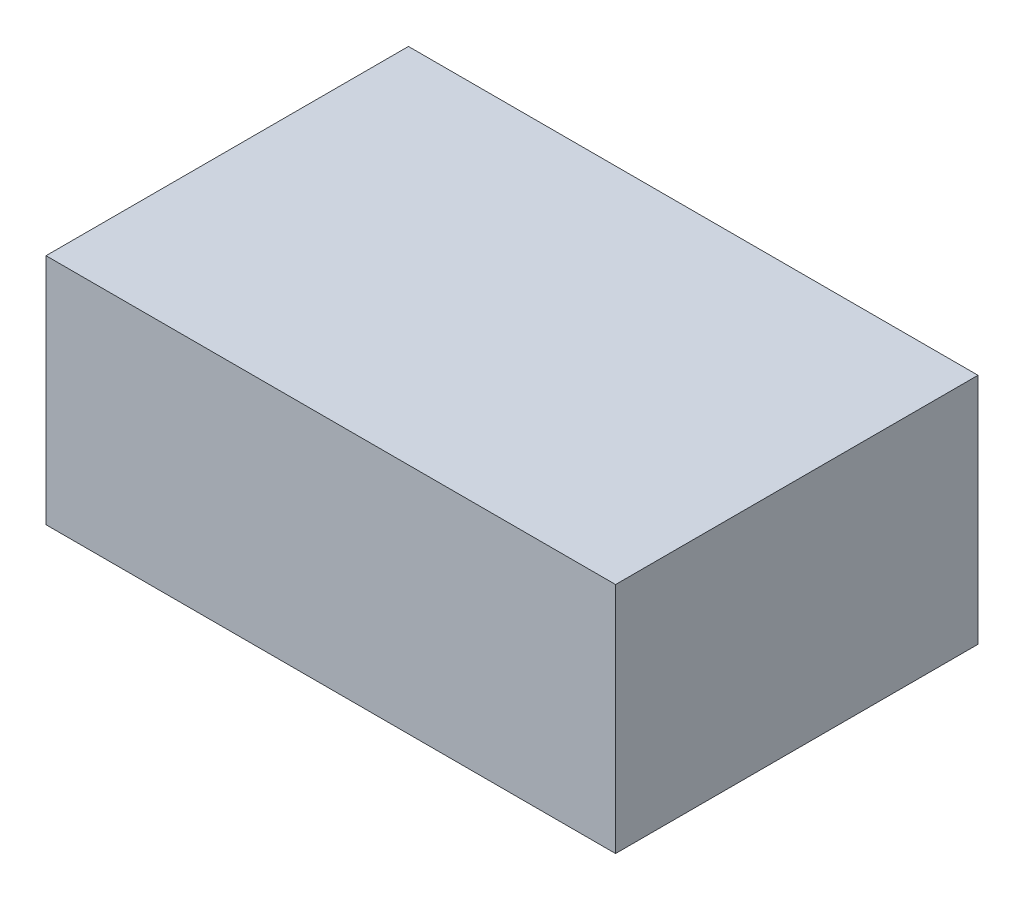
from build123d import *

# Parameters (mm, degrees)
SKETCH1_W           = 69.85
SKETCH1_H           = 44.45
BOSS_EXTRUDE1_DEPTH = 28.575


with BuildPart() as part:
    # Sketch1 → Boss-Extrude1 (new body)
    with BuildSketch(Plane(origin=(0, 0, 0), x_dir=(1, 0, 0), z_dir=(0, 1, 0))):
        Rectangle(SKETCH1_W, SKETCH1_H)
    extrude(amount=BOSS_EXTRUDE1_DEPTH)


solid = part.part
